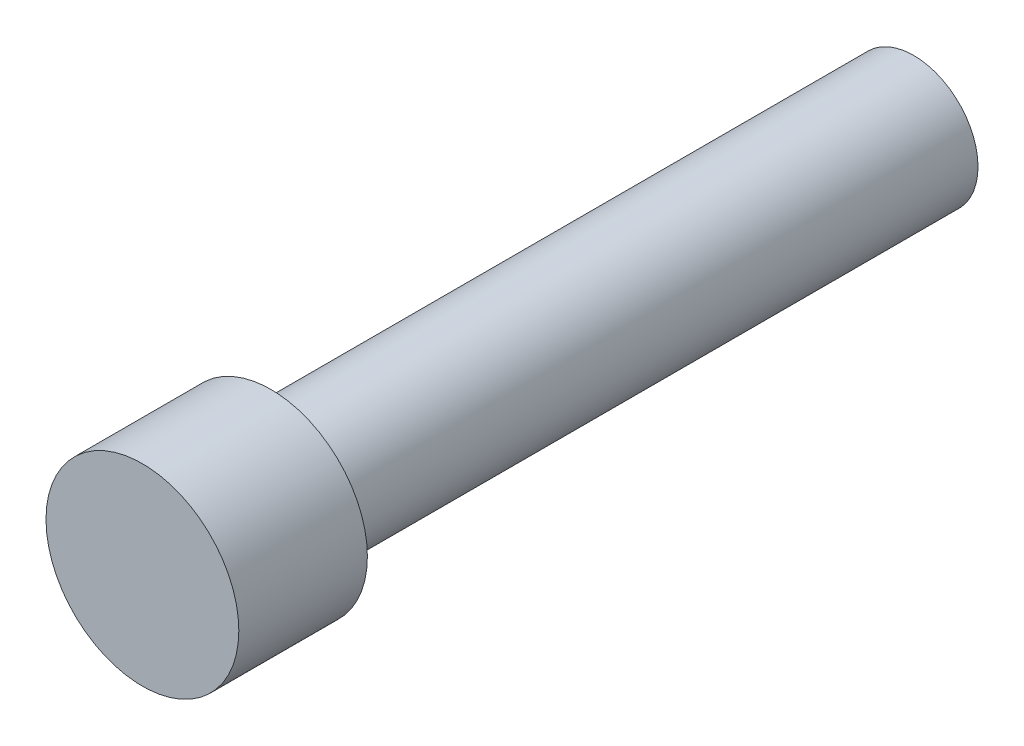
from build123d import *

# Parameters (mm, degrees)
SKETCH1_R           = 0.25
BOSS_EXTRUDE1_DEPTH = 2.5
SKETCH2_R           = 0.375
BOSS_EXTRUDE2_DEPTH = 0.5


with BuildPart() as part:
    # Sketch1 → Boss-Extrude1 (new body)
    with BuildSketch(Plane.XY):
        Circle(SKETCH1_R)
    extrude(amount=BOSS_EXTRUDE1_DEPTH)

    # Sketch2 → Boss-Extrude2 (add)
    with BuildSketch(Plane.XY.offset(2.5)):
        Circle(SKETCH2_R)
    extrude(amount=BOSS_EXTRUDE2_DEPTH)


solid = part.part
